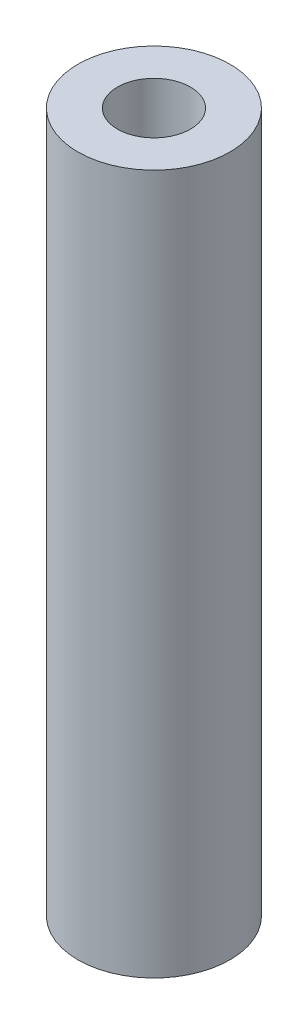
from build123d import *

# Parameters (mm, degrees)
SKETCH1_R           = 2.5
SKETCH1_R_2         = 1.2
BOSS_EXTRUDE1_DEPTH = 23


with BuildPart() as part:
    # Sketch1 → Boss-Extrude1 (new body)
    with BuildSketch(Plane(origin=(0, 0, 0), x_dir=(1, 0, 0), z_dir=(0, 1, 0))):
        Circle(SKETCH1_R)
        Circle(SKETCH1_R_2, mode=Mode.SUBTRACT)
    extrude(amount=BOSS_EXTRUDE1_DEPTH)


solid = part.part
